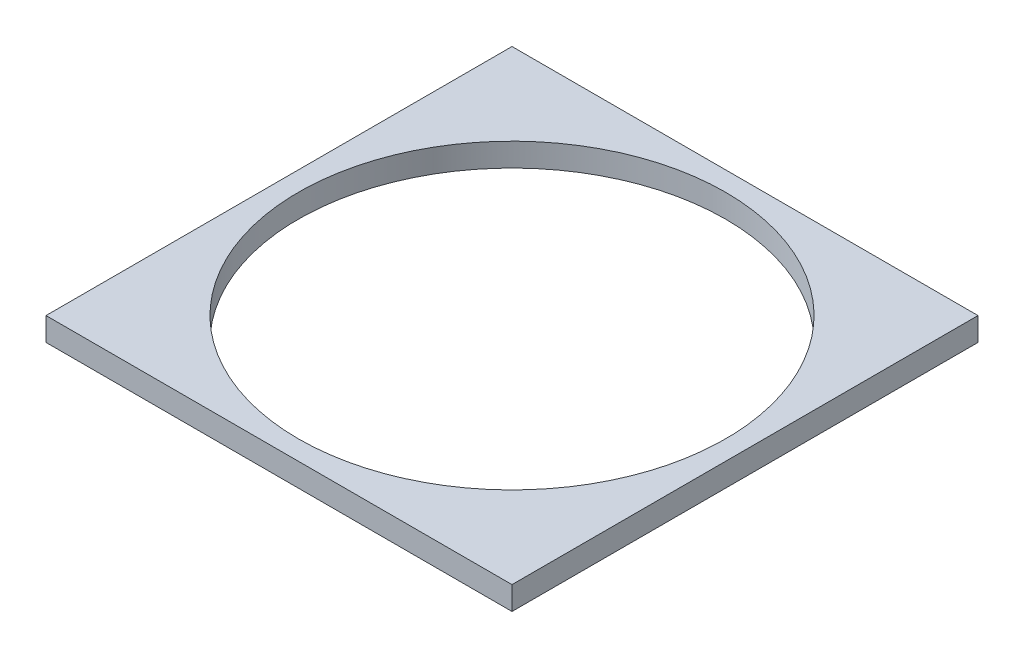
from build123d import *

# Parameters (mm, degrees)
SKETCH2_W           = 152.4
SKETCH2_H           = 152.4
SKETCH2_R           = 69.85
BOSS_EXTRUDE1_DEPTH = 7.62


with BuildPart() as part:
    # Sketch2 → Boss-Extrude1 (new body)
    with BuildSketch(Plane(origin=(0, 0, 0), x_dir=(1, 0, 0), z_dir=(0, 1, 0))):
        Rectangle(SKETCH2_W, SKETCH2_H)
        Circle(SKETCH2_R, mode=Mode.SUBTRACT)
    extrude(amount=BOSS_EXTRUDE1_DEPTH)


solid = part.part
